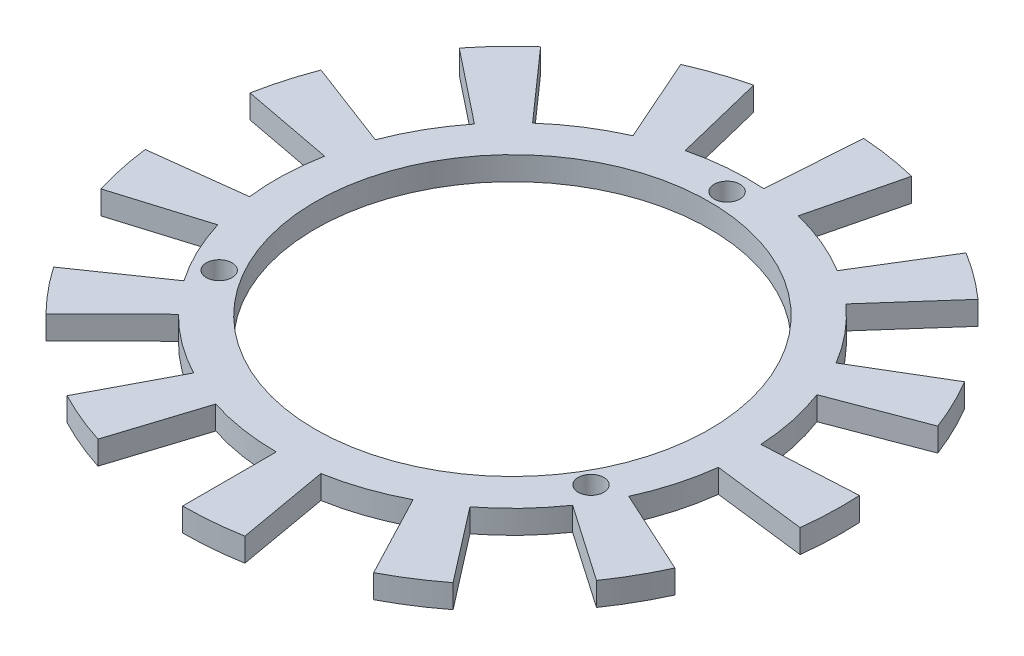
from build123d import *

# Parameters (mm, degrees)
SKETCH1_R           = 30.25
SKETCH1_R_2         = 25.25
EXTRUDE_THIN1_DEPTH = 3
SKETCH2_R           = 1.65
CUT_EXTRUDE3_DEPTH  = 10
BOSS_EXTRUDE1_DEPTH = 3


with BuildPart() as part:
    # Sketch1 → Extrude-Thin1 (new body)
    with BuildSketch(Plane(origin=(0, 0, 0), x_dir=(1, 0, 0), z_dir=(0, 1, 0))):
        Circle(SKETCH1_R)
        Circle(SKETCH1_R_2, mode=Mode.SUBTRACT)
    extrude(amount=-EXTRUDE_THIN1_DEPTH)

    # Sketch2 → Cut-Extrude3 (cut)
    with BuildSketch(Plane(origin=(0, 0, 0), x_dir=(1, 0, 0), z_dir=(0, 1, 0))):
        with Locations((0, 27.5)):
            Circle(SKETCH2_R)
        with Locations((23.815698604, -13.75)):
            Circle(SKETCH2_R)
        with Locations((-23.815698604, -13.75)):
            Circle(SKETCH2_R)
    extrude(amount=-CUT_EXTRUDE3_DEPTH, mode=Mode.SUBTRACT)

    # Sketch5 → Boss-Extrude1 (add)
    with BuildSketch(Plane.XZ.offset(3)):
        with BuildLine():
            Line((0, 42.25), (0, 30.25))
            ThreePointArc((0, 30.25), (2.636461218, 30.134889617), (5.252857374, 29.790434529))
            Line((5.252857374, 29.790434529), (7.336635506, 41.608127565))
            ThreePointArc((7.336635506, 41.608127565), (3.682330131, 42.089225994), (0, 42.25))
        make_face()
        with BuildLine():
            Line((19.634554019, 37.410517084), (14.057875954, 26.785044776))
            ThreePointArc((14.057875954, 26.785044776), (16.338851964, 25.457894974), (18.495479445, 23.936995219))
            Line((18.495479445, 23.936995219), (25.832529142, 33.432662744))
            ThreePointArc((25.832529142, 33.432662744), (22.820380016, 35.556894633), (19.634554019, 37.410517084))
        make_face()
        with BuildLine():
            Line((34.771068334, 24.000735549), (24.895261943, 17.183958589))
            ThreePointArc((24.895261943, 17.183958589), (26.29820863, 14.948803393), (27.501010069, 12.599878777))
            Line((27.501010069, 12.599878777), (38.410501667, 17.598177795))
            ThreePointArc((38.410501667, 17.598177795), (36.730555855, 20.878907218), (34.771068334, 24.000735549))
        make_face()
        with BuildLine():
            Line((41.941949931, 5.092674741), (30.029443441, 3.646234578))
            ThreePointArc((30.029443441, 3.646234578), (30.232962626, 1.015121107), (30.20639071, -1.623718049))
            Line((30.20639071, -1.623718049), (42.189091156, -2.267837605))
            ThreePointArc((42.189091156, -2.267837605), (42.226203998, 1.417813777), (41.941949931, 5.092674741))
        make_face()
        with BuildLine():
            Line((39.504436253, -14.982056478), (28.284241341, -10.726797833))
            ThreePointArc((28.284241341, -10.726797833), (27.241709231, -13.151113191), (25.991851265, -15.475340637))
            Line((25.991851265, -15.475340637), (36.302668296, -21.61431874))
            ThreePointArc((36.302668296, -21.61431874), (38.048337687, -18.368083713), (39.504436253, -14.982056478))
        make_face()
        with BuildLine():
            Line((28.016932311, -31.62457911), (20.059460412, -22.642450132))
            ThreePointArc((20.059460412, -22.642450132), (18.00970855, -24.304585945), (15.822891931, -25.781749183))
            Line((15.822891931, -25.781749183), (22.099741623, -36.009219933))
            ThreePointArc((22.099741623, -36.009219933), (25.154055743, -33.946074584), (28.016932311, -31.62457911))
        make_face()
        with BuildLine():
            Line((10.111086816, -41.022291786), (7.239298845, -29.370989977))
            ThreePointArc((7.239298845, -29.370989977), (4.65190068, -29.890170961), (2.029098743, -30.181869695))
            Line((2.029098743, -30.181869695), (2.834030476, -42.154842797))
            ThreePointArc((2.834030476, -42.154842797), (6.497282768, -41.747428862), (10.111086816, -41.022291786))
        make_face()
        with BuildLine():
            Line((-10.111086816, -41.022291786), (-7.239298845, -29.370989977))
            ThreePointArc((-7.239298845, -29.370989977), (-9.771601574, -28.628278025), (-12.229536514, -27.667687591))
            Line((-12.229536514, -27.667687591), (-17.0809229, -38.643299198))
            ThreePointArc((-17.0809229, -38.643299198), (-13.647939388, -39.9849503), (-10.111086816, -41.022291786))
        make_face()
        with BuildLine():
            Line((-28.016932311, -31.62457911), (-20.059460412, -22.642450132))
            ThreePointArc((-20.059460412, -22.642450132), (-21.956547668, -20.807991602), (-23.686532338, -18.815171692))
            Line((-23.686532338, -18.815171692), (-33.082842687, -26.279041454))
            ThreePointArc((-33.082842687, -26.279041454), (-30.666583106, -29.062401494), (-28.016932311, -31.62457911))
        make_face()
        with BuildLine():
            Line((-39.504436253, -14.982056478), (-28.284241341, -10.726797833))
            ThreePointArc((-28.284241341, -10.726797833), (-29.111513296, -8.220845067), (-29.717229057, -5.652326705))
            Line((-29.717229057, -5.652326705), (-41.505881906, -7.89457201))
            ThreePointArc((-41.505881906, -7.89457201), (-40.659882207, -11.482006746), (-39.504436253, -14.982056478))
        make_face()
        with BuildLine():
            Line((-41.941949931, 5.092674741), (-30.029443441, 3.646234578))
            ThreePointArc((-30.029443441, 3.646234578), (-29.59738206, 6.249598002), (-28.94006673, 8.805398211))
            Line((-28.94006673, 8.805398211), (-40.42042378, 12.298448742))
            ThreePointArc((-40.42042378, 12.298448742), (-41.338492299, 8.728777374), (-41.941949931, 5.092674741))
        make_face()
        with BuildLine():
            Line((-34.771068334, 24.000735549), (-24.895261943, 17.183958589))
            ThreePointArc((-24.895261943, 17.183958589), (-23.302847281, 19.288333484), (-21.533083881, 21.245912515))
            Line((-21.533083881, 21.245912515), (-30.075133685, 29.674043099))
            ThreePointArc((-30.075133685, 29.674043099), (-32.546951988, 26.939903791), (-34.771068334, 24.000735549))
        make_face()
        with BuildLine():
            Line((-19.634554019, 37.410517084), (-14.057875954, 26.785044776))
            ThreePointArc((-14.057875954, 26.785044776), (-11.66991102, 27.908344214), (-9.193131017, 28.819244302))
            Line((-9.193131017, 28.819244302), (-12.839992908, 40.251671793))
            ThreePointArc((-12.839992908, 40.251671793), (-16.29929721, 38.979422911), (-19.634554019, 37.410517084))
        make_face()
    extrude(amount=-BOSS_EXTRUDE1_DEPTH)


solid = part.part
